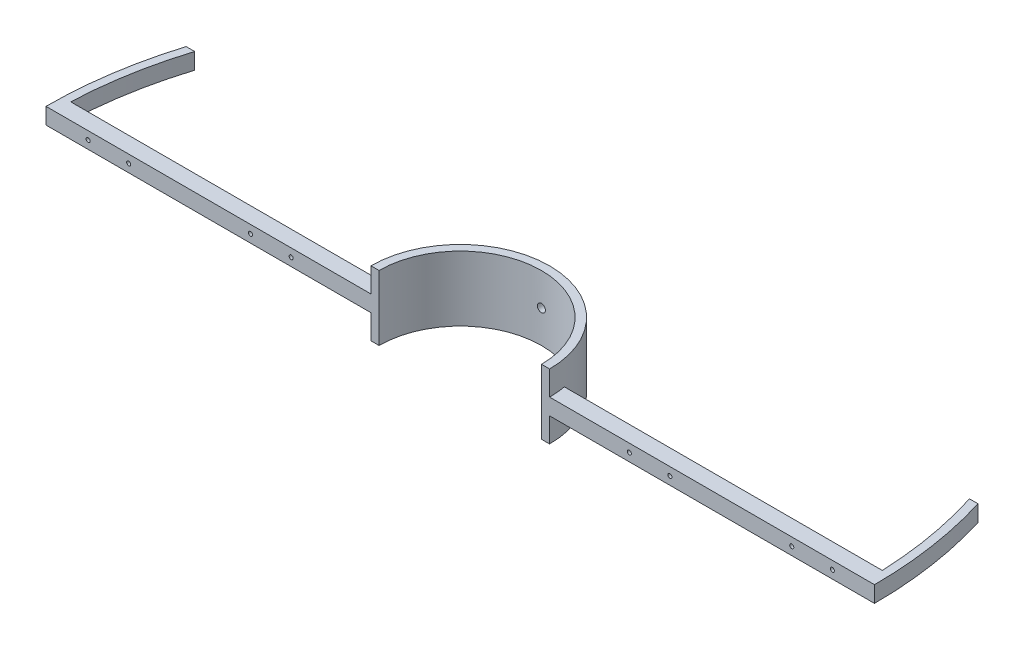
from build123d import *

# Parameters (mm, degrees)
BOSS_EXTRUDE1_DEPTH = 80
SKETCH2_W           = 20
SKETCH2_H           = 10
BOSS_EXTRUDE2_DEPTH = 400
SKETCH3_W           = 20
SKETCH3_H           = 20
BOSS_EXTRUDE3_DEPTH = 400
BOSS_EXTRUDE4_DEPTH = 20
BOSS_EXTRUDE5_DEPTH = 20
SKETCH8_R           = 2.5
CUT_EXTRUDE1_DEPTH  = 20
CUT_EXTRUDE3_DEPTH  = 20


with BuildPart() as part:
    # Sketch1 → Boss-Extrude1 (new body)
    with BuildSketch(Plane(origin=(0, 0, 0), x_dir=(1, 0, 0), z_dir=(0, 1, 0))):
        with BuildLine():
            Line((-110, 0), (-100, 0))
            ThreePointArc((-100, 0), (0, 100), (100, 0))
            Line((100, 0), (110, 0))
            ThreePointArc((110, 0), (0, 110), (-110, 0))
        make_face()
    extrude(amount=BOSS_EXTRUDE1_DEPTH)

    # Sketch2 → Boss-Extrude2 (add)
    with BuildSketch(Plane(origin=(100, 80, 0), x_dir=(0, 0, 1), z_dir=(-1, 0, 0))):
        with Locations((-10, -35)):
            Rectangle(SKETCH2_W, SKETCH2_H)
        with Locations((-10, -45)):
            Rectangle(SKETCH2_W, SKETCH2_H)
    extrude(amount=-BOSS_EXTRUDE2_DEPTH)

    # Sketch3 → Boss-Extrude3 (add)
    with BuildSketch(Plane(origin=(-100, 80, 0), x_dir=(0, 0, -1), z_dir=(1, 0, 0))):
        with Locations((10, -40)):
            Rectangle(SKETCH3_W, SKETCH3_H)
    extrude(amount=-BOSS_EXTRUDE3_DEPTH)

    # Sketch5 → Boss-Extrude4 (add)
    with BuildSketch(Plane(origin=(0, 50, 0), x_dir=(1, 0, 0), z_dir=(0, 1, 0))):
        with BuildLine():
            Line((500, 0), (510, 0))
            ThreePointArc((510, 0), (504.329046943, 75.843341231), (487.442304278, 150))
            Line((487.442304278, 150), (476.969600708, 150))
            ThreePointArc((476.969600708, 150), (494.208862908, 75.878849641), (500, 0))
        make_face()
    extrude(amount=-BOSS_EXTRUDE4_DEPTH)

    # Sketch7 → Boss-Extrude5 (add)
    with BuildSketch(Plane(origin=(0, 50, 0), x_dir=(1, 0, 0), z_dir=(0, 1, 0))):
        with BuildLine():
            ThreePointArc((-510, 0), (-504.329046943, 75.843341231), (-487.442304278, 150))
            Line((-487.442304278, 150), (-476.969600708, 150))
            ThreePointArc((-476.969600708, 150), (-494.208862908, 75.878849641), (-500, 0))
            Line((-500, 0), (-510, 0))
        make_face()
    extrude(amount=-BOSS_EXTRUDE5_DEPTH)

    # Sketch8 → Cut-Extrude1 (cut)
    with BuildSketch(Plane(origin=(0, 0, -20), x_dir=(-1, 0, 0), z_dir=(0, 0, -1))):
        with Locations((-408.166538264, 40)):
            Circle(SKETCH8_R)
        with Locations((-258.166538264, 40)):
            Circle(SKETCH8_R)
        with Locations((258.166538264, 40)):
            Circle(SKETCH8_R)
        with Locations((408.166538264, 40)):
            Circle(SKETCH8_R)
        with Locations((-458.166538264, 40)):
            Circle(SKETCH8_R)
        with Locations((-208.166538264, 40)):
            Circle(SKETCH8_R)
        with Locations((208.166538264, 40)):
            Circle(SKETCH8_R)
        with Locations((458.166538264, 40)):
            Circle(SKETCH8_R)
    extrude(amount=-CUT_EXTRUDE1_DEPTH, mode=Mode.SUBTRACT)

    # Sketch9 → Cut-Extrude3 (cut)
    with BuildSketch(Plane(origin=(0, 80, -110), x_dir=(-1, 0, 0), z_dir=(0, 0, -1))):
        with BuildLine():
            ThreePointArc((0, -35), (-5, -40), (0, -45))
            Line((0, -45), (0, -35))
        make_face()
        with BuildLine():
            Line((0, -35), (0, -45))
            ThreePointArc((0, -45), (3.535533906, -43.535533906), (5, -40))
            ThreePointArc((5, -40), (3.535533906, -36.464466094), (0, -35))
        make_face()
    extrude(amount=-CUT_EXTRUDE3_DEPTH, mode=Mode.SUBTRACT)


solid = part.part
